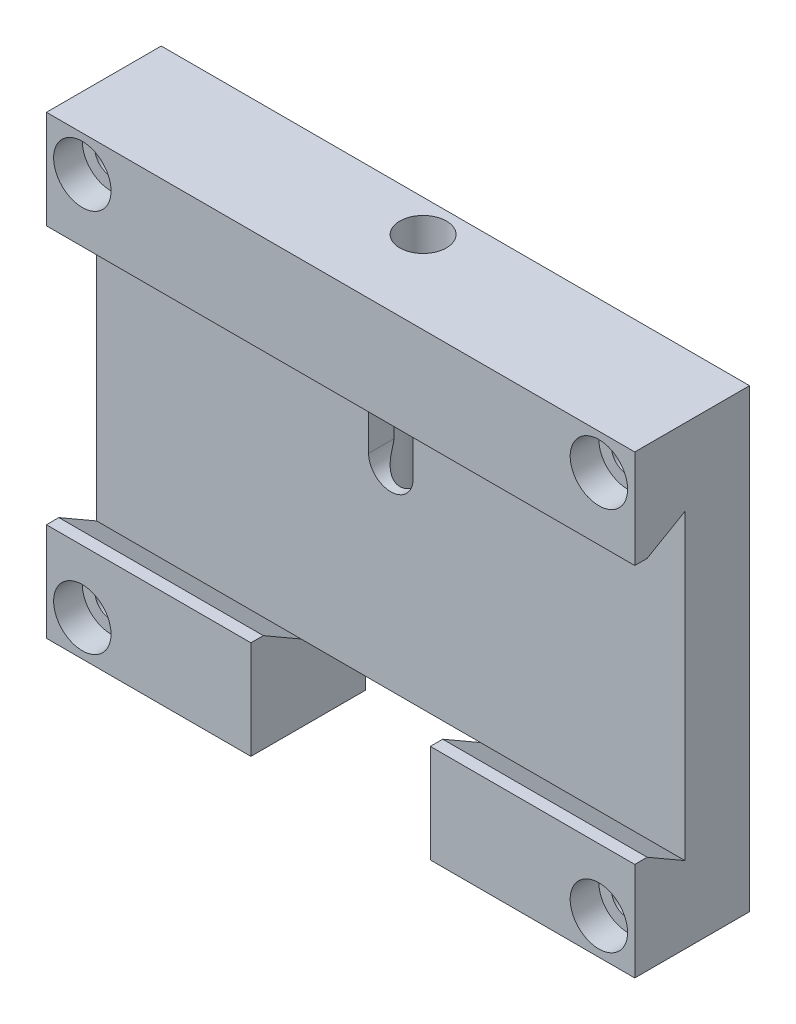
from build123d import *

# Parameters (mm, degrees)
SKETCH_1_W                  = 82
SKETCH_1_H                  = 63.5
EXTRUDE_1_DEPTH             = 16
CUT_EXTRUDE_1_DEPTH         = 83
SKETCH_15_W                 = 25
SKETCH_15_H                 = 14.711451884
CUT_EXTRUDE_4_DEPTH         = 7
SKETCH_16_W                 = 25
SKETCH_16_H                 = 10.67
CUT_EXTRUDE_5_DEPTH         = 9
SKETCH_17_R                 = 2.5
CUT_EXTRUDE_6_DEPTH         = 4
M4X0_72_D                   = 3.3
M4X0_72_DEPTH               = 10
M4X0_72_TIP                 = 0.991420021
CUT_EXTRUDE_7_DEPTH         = 4
SKETCH_26_R                 = 3.25
CUT_EXTRUDE_8_DEPTH         = 38
HOLE_WIZARD_M41_D           = 4.5
HOLE_WIZARD_M41_CBORE_D     = 8
HOLE_WIZARD_M41_CBORE_DEPTH = 4
CHAMFER_2_SIZE              = 1
CHAMFER_2_SIZE2             = 2
CHAMFER_2_PART_2_SIZE       = 1
CHAMFER_2_PART_2_SIZE2      = 2
CHAMFER_2_PART_3_SIZE       = 1
CHAMFER_2_PART_3_SIZE2      = 2


with BuildPart() as part:
    # Эскиз1 → Бобышка-Вытянуть1 (new body)
    with BuildSketch(Plane.XY):
        with Locations((41, -31.75)):
            Rectangle(SKETCH_1_W, SKETCH_1_H)
    extrude(amount=EXTRUDE_1_DEPTH)

    # Эскиз2 → Вырез-Вытянуть1 (cut, through all)
    with BuildSketch(Plane.ZY):
        Polygon((9, -10.67), (16, -14.711451884), (16, -48.788548116), (9, -52.83), align=None)
    extrude(amount=-CUT_EXTRUDE_1_DEPTH, mode=Mode.SUBTRACT)

    # Эскиз15 → Вырез-Вытянуть4 (cut)
    with BuildSketch(Plane.XY.offset(16)):
        with Locations((41, -56.144274058)):
            Rectangle(SKETCH_15_W, SKETCH_15_H)
    extrude(amount=-CUT_EXTRUDE_4_DEPTH, mode=Mode.SUBTRACT)

    # Эскиз16 → Вырез-Вытянуть5 (cut)
    with BuildSketch(Plane.XY.offset(9)):
        with Locations((41, -58.165)):
            Rectangle(SKETCH_16_W, SKETCH_16_H)
    extrude(amount=-CUT_EXTRUDE_5_DEPTH, mode=Mode.SUBTRACT)

    # Эскиз17 → Вырез-Вытянуть6 (cut)
    with BuildSketch(Plane.XZ.offset(52.83)):
        with Locations((33.5, 5)):
            Circle(SKETCH_17_R)
        with Locations((48.5, 5)):
            Circle(SKETCH_17_R)
    extrude(amount=-CUT_EXTRUDE_6_DEPTH, mode=Mode.SUBTRACT)

    # Отверстие обработанное метчиком M4x0.72
    with Locations(Plane(origin=(0, -52.83, 0), x_dir=(-1, 0, 0), z_dir=(0, -1, 0))):
        with Locations((-41, -5)):
            Hole(M4X0_72_D / 2, depth=M4X0_72_DEPTH)
            with Locations((0, 0, -(M4X0_72_DEPTH + M4X0_72_TIP / 2))):  # 118° drill point
                Cone(0, M4X0_72_D / 2, M4X0_72_TIP, mode=Mode.SUBTRACT)

    # Эскиз25 → Вырез-Вытянуть7 (cut)
    with BuildSketch(Plane.XY.offset(9)):
        with BuildLine():
            Line((44.1, -18.711451884), (44.1, -25.711451884))
            ThreePointArc((44.1, -25.711451884), (41, -28.811451884), (37.9, -25.711451884))
            Line((37.9, -25.711451884), (37.9, -18.711451884))
            ThreePointArc((37.9, -18.711451884), (41, -15.611451884), (44.1, -18.711451884))
        make_face()
    extrude(amount=-CUT_EXTRUDE_7_DEPTH, mode=Mode.SUBTRACT)

    # Эскиз26 → Вырез-Вытянуть8 (cut)
    with BuildSketch(Plane(origin=(0, 0, 0), x_dir=(1, 0, 0), z_dir=(0, 1, 0))):
        with Locations((41, -4.5)):
            Circle(SKETCH_26_R)
    extrude(amount=-CUT_EXTRUDE_8_DEPTH, mode=Mode.SUBTRACT)

    # Цековка для винта с внутренним шестигранником M41 (through all)
    with Locations(Plane(origin=(30.759227947, 26.793365177, 16), x_dir=(-1, 0, 0), z_dir=(0, 0, 1))):
        with Locations((-46.240772053, 31.793365177), (-46.240772053, 85.293365177), (25.759227947, 85.293365177), (25.759227947, 31.793365177)):
            CounterBoreHole(HOLE_WIZARD_M41_D / 2, HOLE_WIZARD_M41_CBORE_D / 2, HOLE_WIZARD_M41_CBORE_DEPTH)

    # Фаска2
    chamfer_2_edges = [part.edges().sort_by_distance(p)[0] for p in [
        (41, -14.711451884, 16),
    ]]
    chamfer_2_side = [part.faces().sort_by_distance(p)[0] for p in [
        (41, -7.569889145, 16),
    ]]
    chamfer(chamfer_2_edges, length=CHAMFER_2_SIZE, length2=CHAMFER_2_SIZE2, reference=chamfer_2_side[0])

    # Фаска2 part 2
    chamfer_2_part_2_edges = [part.edges().sort_by_distance(p)[0] for p in [
        (67.75, -48.788548116, 16),
    ]]
    chamfer_2_part_2_side = [part.faces().sort_by_distance(p)[0] for p in [
        (66.489994625, -55.823384615, 16),
    ]]
    chamfer(chamfer_2_part_2_edges, length=CHAMFER_2_PART_2_SIZE, length2=CHAMFER_2_PART_2_SIZE2, reference=chamfer_2_part_2_side[0])

    # Фаска2 part 3
    chamfer_2_part_3_edges = [part.edges().sort_by_distance(p)[0] for p in [
        (14.25, -48.788548116, 16),
    ]]
    chamfer_2_part_3_side = [part.faces().sort_by_distance(p)[0] for p in [
        (15.510005375, -55.823384615, 16),
    ]]
    chamfer(chamfer_2_part_3_edges, length=CHAMFER_2_PART_3_SIZE, length2=CHAMFER_2_PART_3_SIZE2, reference=chamfer_2_part_3_side[0])


solid = part.part
